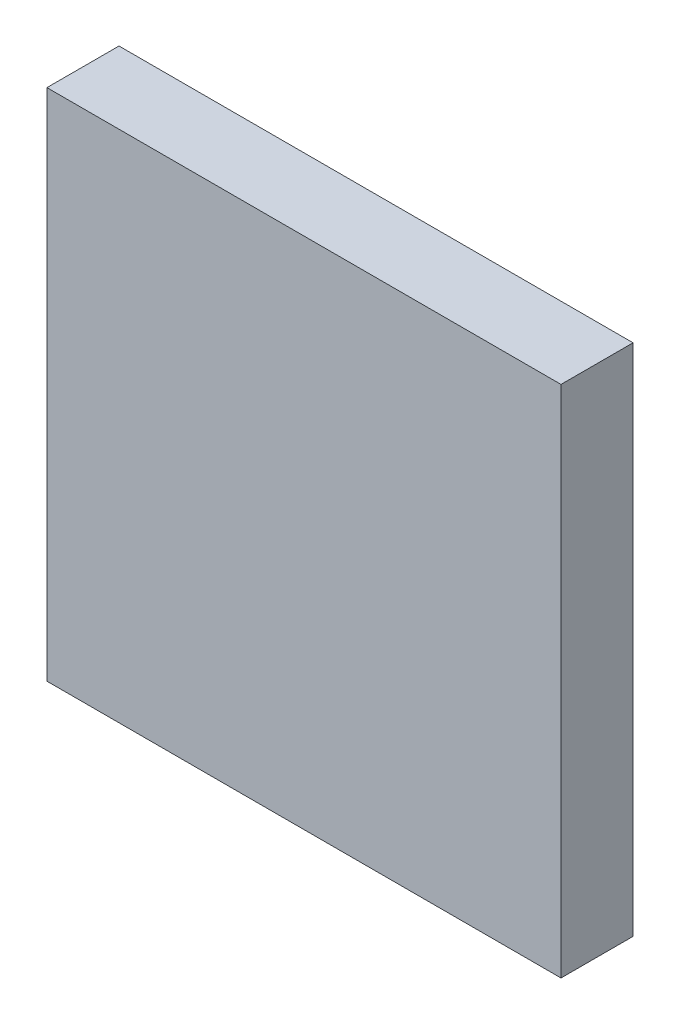
from build123d import *

# Parameters (mm, degrees)
SKETCH3_W           = 107
SKETCH3_H           = 107
BOSS_EXTRUDE2_DEPTH = 15


with BuildPart() as part:
    # Sketch3 → Boss-Extrude2 (new body)
    with BuildSketch(Plane.XY):
        with Locations((147.268190706, -97.834558617)):
            Rectangle(SKETCH3_W, SKETCH3_H)
    extrude(amount=BOSS_EXTRUDE2_DEPTH)


solid = part.part
